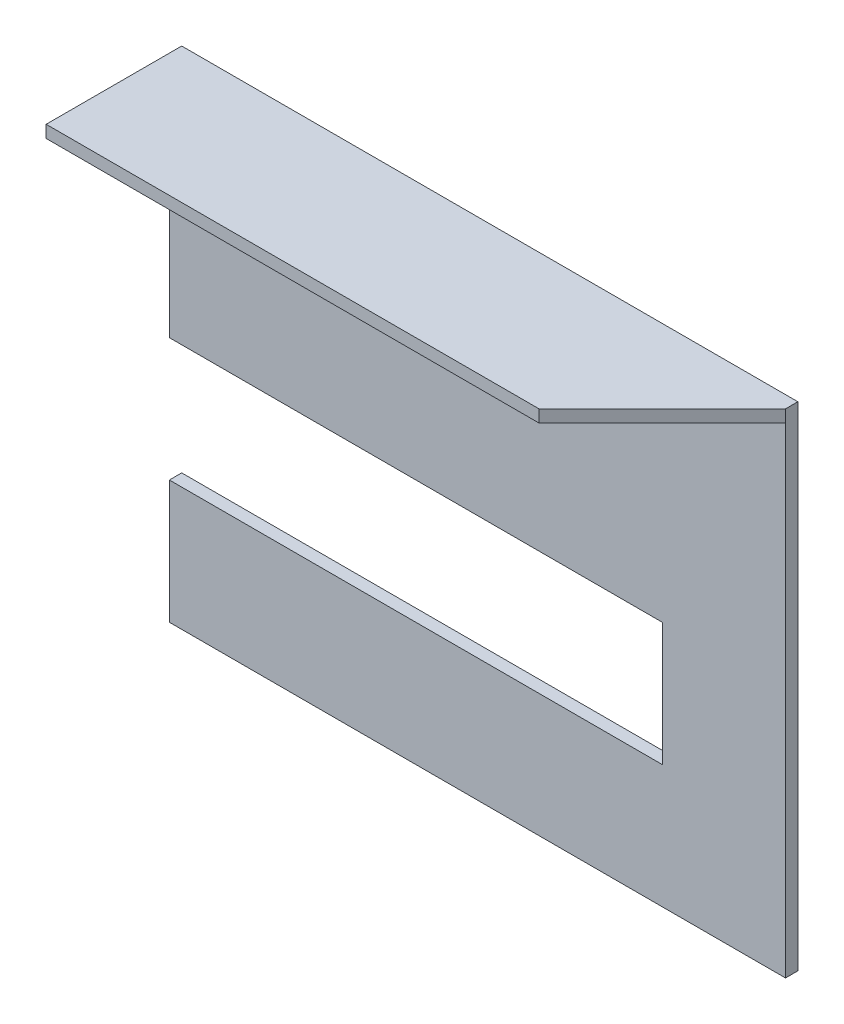
from build123d import *

# Parameters (mm, degrees)
EXTRUDE_1_DEPTH = 1
SKETCH_2_W      = 50
SKETCH_2_H      = 1
EXTRUDE_2_DEPTH = 10
CHAMFER_1_SIZE  = 10


with BuildPart() as part:
    # 草图1 → 凸台-拉伸1 (new body)
    with BuildSketch(Plane.XY):
        Polygon((23.496790028, -8.332562617), (23.496790028, -17.864815409), (23.496790028, -30.601283989), (-26.503209972, -30.601283989), (-26.503209972, -20.601283989), (13.496790028, -20.601283989), (13.496790028, -10.601283989), (-26.503209972, -10.601283989), (-26.503209972, 9.398716011), (23.496790028, 9.398716011), align=None)
    extrude(amount=EXTRUDE_1_DEPTH)

    # 草图2 → 凸台-拉伸2 (add)
    with BuildSketch(Plane.XY.offset(1)):
        with Locations((-1.503209972, 8.898716011)):
            Rectangle(SKETCH_2_W, SKETCH_2_H)
    extrude(amount=EXTRUDE_2_DEPTH)

    # 倒角1
    chamfer_1_edges = [part.edges().sort_by_distance(p)[0] for p in [
        (23.496790028, 8.898716011, 11),
    ]]
    chamfer(chamfer_1_edges, length=CHAMFER_1_SIZE)


solid = part.part
